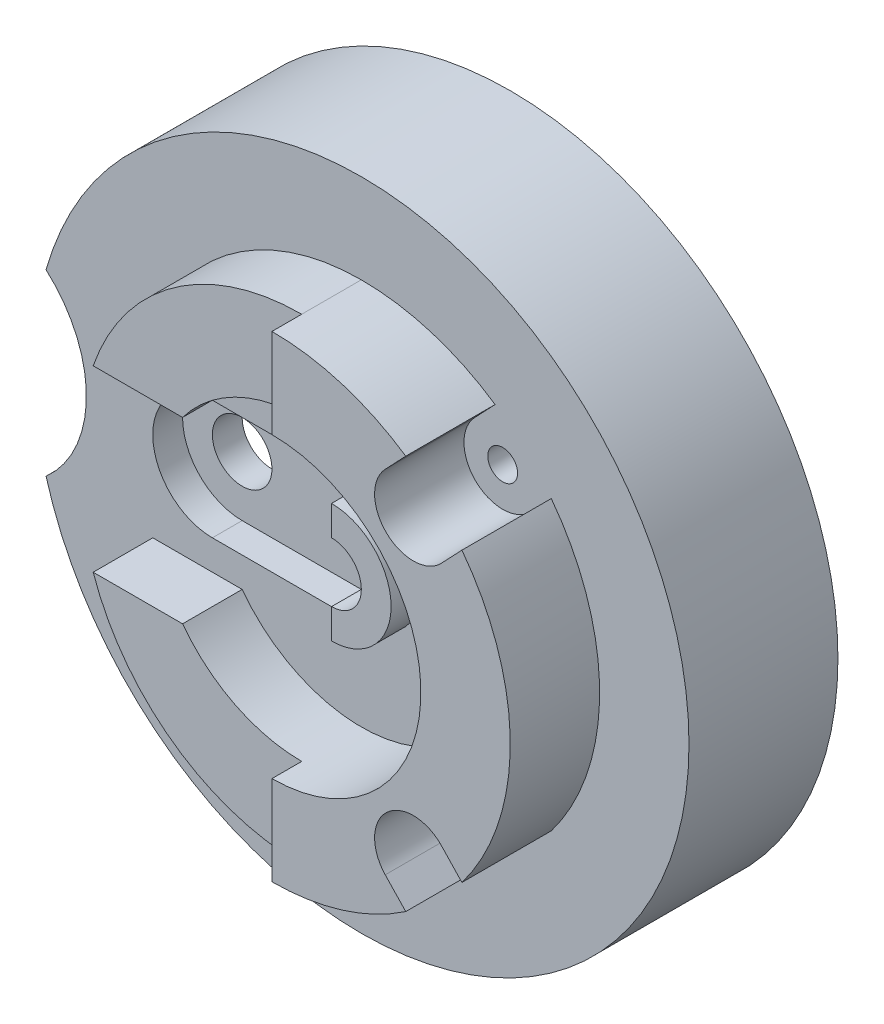
from build123d import *
from build123d.topology import SkipClean

# Parameters (mm, degrees)
SKETCH3_R           = 55
BOSS_EXTRUDE2_DEPTH = 25
SKETCH4_R           = 50
CUT_EXTRUDE1_DEPTH  = 15
CUT_EXTRUDE2_START  = -15
CUT_EXTRUDE2_DEPTH  = 15
BOSS_EXTRUDE3_DEPTH = 10
BOSS_EXTRUDE4_DEPTH = 10
BOSS_EXTRUDE5_DEPTH = 15
CUT_EXTRUDE4_START  = -15
CUT_EXTRUDE4_DEPTH  = 15
SKETCH11_R          = 2.5
CUT_EXTRUDE7_DEPTH  = 25
SKETCH12_R          = 2.5
CUT_EXTRUDE9_DEPTH  = 10
CUT_EXTRUDE12_DEPTH = 5
SKETCH14_R          = 5
CUT_EXTRUDE13_DEPTH = 10
BOSS_EXTRUDE6_START = 10
BOSS_EXTRUDE6_DEPTH = 10


with BuildPart() as part:
    # Sketch3 → Boss-Extrude2 (new body)
    with BuildSketch(Plane.XY):
        Circle(SKETCH3_R)
    extrude(amount=BOSS_EXTRUDE2_DEPTH)

    # Sketch4 → Cut-Extrude1 (cut)
    with BuildSketch(Plane(origin=(0, 0, 0), x_dir=(-1, 0, 0), z_dir=(0, 0, -1))):
        Circle(SKETCH4_R)
    extrude(amount=-CUT_EXTRUDE1_DEPTH, mode=Mode.SUBTRACT)

    # Sketch5 → Cut-Extrude2 (cut)
    with BuildSketch(Plane.XY.offset(25).offset(CUT_EXTRUDE2_START)):
        with BuildLine():
            ThreePointArc((-52.915026221, 15), (-46.143782777, 0), (-52.915026221, -15))
            ThreePointArc((-52.915026221, -15), (-55, 0), (-52.915026221, 15))
        make_face()
    extrude(amount=CUT_EXTRUDE2_DEPTH, mode=Mode.SUBTRACT)

    # Sketch6 → Boss-Extrude3 (add)
    with BuildSketch(Plane.XY.offset(25)):
        with BuildLine():
            Line((-35, 15), (-20, 15))
            ThreePointArc((-20, 15), (-11.180339887, 22.360679775), (0, 25))
            Line((0, 25), (0, 40))
            ThreePointArc((0, 40), (-21.505813168, 33.108138435), (-35, 15))
        make_face()
    extrude(amount=BOSS_EXTRUDE3_DEPTH)

    # Sketch7 → Boss-Extrude4 (add)
    with BuildSketch(Plane.XY.offset(25)):
        with BuildLine():
            Line((-35, -15), (-20, -15))
            ThreePointArc((-20, -15), (-11.180339887, -22.360679775), (0, -25))
            Line((0, -25), (0, -40))
            ThreePointArc((0, -40), (-21.505813168, -33.108138435), (-35, -15))
        make_face()
    extrude(amount=BOSS_EXTRUDE4_DEPTH)

    # Sketch8 → Boss-Extrude5 (add)
    with SkipClean():  # the faces are left unmerged after this step: merging them gives an invalid solid
        with BuildSketch(Plane.XY.offset(25)):
            with BuildLine():
                Line((0, -40), (0, -25))
                ThreePointArc((0, -25), (25, 0), (0, 25))
                Line((0, 25), (0, 40))
                ThreePointArc((0, 40), (40, 0), (0, -40))
            make_face()
        extrude(amount=BOSS_EXTRUDE5_DEPTH)

    # Sketch9 → Cut-Extrude4 (cut)
    with SkipClean():  # the faces are left unmerged after this step: merging them gives an invalid solid
        with BuildSketch(Plane.XY.offset(40).offset(CUT_EXTRUDE4_START)):
            with BuildLine():
                Line((19.014552984, -29.474791897), (22.456700597, -33.101308106))
                ThreePointArc((22.456700597, -33.101308106), (27.537180907, -29.012129665), (31.885642738, -24.151724311))
                Line((31.885642738, -24.151724311), (28.443495125, -20.525208103))
                ThreePointArc((28.443495125, -20.525208103), (19.254232157, -20.285528929), (19.014552984, -29.474791897))
            make_face()
            with BuildLine():
                Line((22.456700597, 33.101308106), (19.014552984, 29.474791897))
                ThreePointArc((19.014552984, 29.474791897), (19.254232157, 20.285528929), (28.443495125, 20.525208103))
                Line((28.443495125, 20.525208103), (31.885642738, 24.151724311))
                ThreePointArc((31.885642738, 24.151724311), (27.537180907, 29.012129665), (22.456700597, 33.101308106))
            make_face()
        extrude(amount=CUT_EXTRUDE4_DEPTH, mode=Mode.SUBTRACT)

    # Sketch11 → Cut-Extrude7 (cut)
    with SkipClean():  # the faces are left unmerged after this step: merging them gives an invalid solid
        with BuildSketch(Plane.XY.offset(25)):
            with Locations((23.729024054, -25)):
                Circle(SKETCH11_R)
            with Locations((23.729024054, 25)):
                Circle(SKETCH11_R)
        extrude(amount=-CUT_EXTRUDE7_DEPTH, mode=Mode.SUBTRACT)

    # Sketch12 → Cut-Extrude9 (cut)
    with SkipClean():  # the faces are left unmerged after this step: merging them gives an invalid solid
        with BuildSketch(Plane.XY.offset(25)):
            with Locations((15, 0)):
                Circle(SKETCH12_R)
        extrude(amount=-CUT_EXTRUDE9_DEPTH, mode=Mode.SUBTRACT)

    # Sketch13 → Cut-Extrude12 (cut)
    with SkipClean():  # the faces are left unmerged after this step: merging them gives an invalid solid
        with BuildSketch(Plane.XY.offset(25)):
            with BuildLine():
                Line((-25, 10), (0, 10))
                ThreePointArc((0, 10), (10, 0), (0, -10))
                Line((0, -10), (-25, -10))
                ThreePointArc((-25, -10), (-35, 0), (-25, 10))
            make_face()
        extrude(amount=-CUT_EXTRUDE12_DEPTH, mode=Mode.SUBTRACT)

    # Sketch14 → Cut-Extrude13 (cut)
    with SkipClean():  # the faces are left unmerged after this step: merging them gives an invalid solid
        with BuildSketch(Plane.XY.offset(20)):
            with Locations((-25, 0)):
                Circle(SKETCH14_R)
            Circle(SKETCH14_R)
        extrude(amount=-CUT_EXTRUDE13_DEPTH, mode=Mode.SUBTRACT)

    # Sketch15 → Boss-Extrude6 (add)
    with SkipClean():  # the faces are left unmerged after this step: merging them gives an invalid solid
        with BuildSketch(Plane.XY.offset(20).offset(BOSS_EXTRUDE6_START)):
            with BuildLine():
                Line((0, 5), (0, 10))
                ThreePointArc((0, 10), (10, 0), (0, -10))
                Line((0, -10), (0, -5))
                ThreePointArc((0, -5), (5, 0), (0, 5))
            make_face()
        extrude(amount=-BOSS_EXTRUDE6_DEPTH)


solid = part.part
